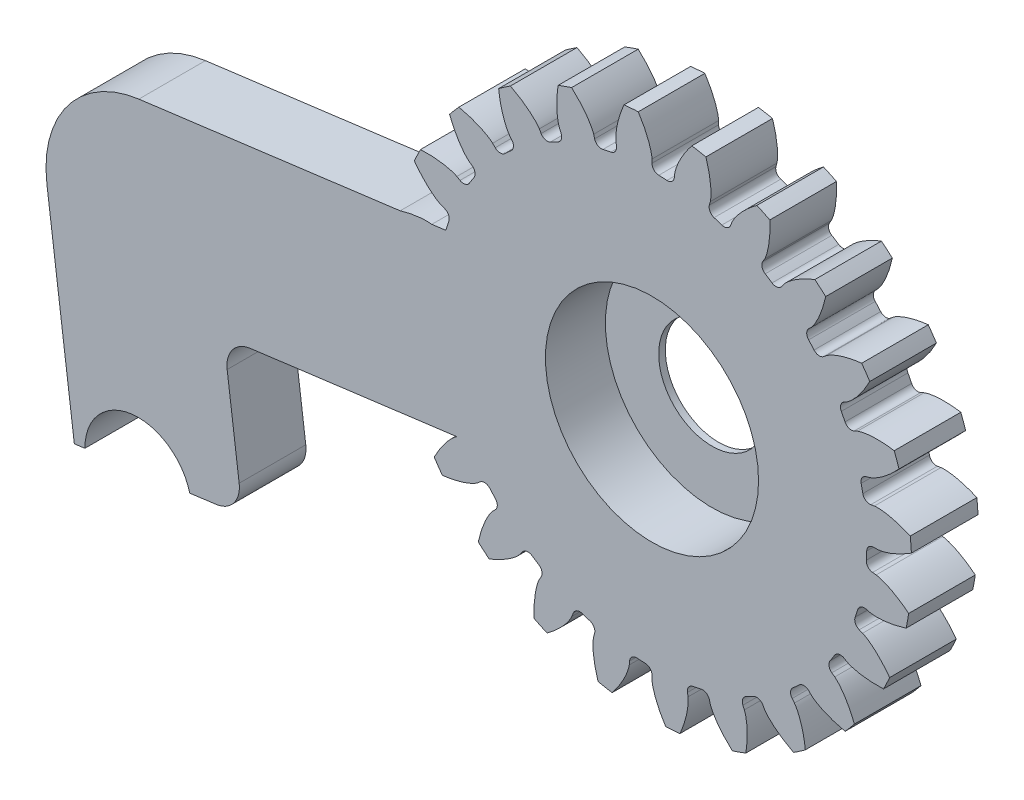
from build123d import *

# Parameters (mm, degrees)
SKETCH_1_R                       = 19.5
EXTRUDE_1_DEPTH                  = 2.5
CUT_EXTRUDE_1_DEPTH              = 3.5
FILLET_1_R                       = 0.525
PATTERN_CIRCULAR_1_COUNT         = 24
FILLET_1_OF_PATTERN_CIRCULAR_1_R = 0.525
SKETCH_7_R                       = 1.25
CUT_EXTRUDE_3_DEPTH              = 10
SKETCH_8_R                       = 8
CUT_EXTRUDE_4_DEPTH              = 4.5
SKETCH_9_R                       = 4
CUT_EXTRUDE_5_DEPTH              = 4
EXTRUDE_2_DEPTH                  = 5
FILLET_2_R                       = 2
FILLET_3_R                       = 2
FILLET_4_R                       = 8


with BuildPart() as part:
    # 草图1 → 凸台-拉伸1 (new body, symmetric)
    with BuildSketch(Plane.XY):
        Circle(SKETCH_1_R)
    extrude(amount=EXTRUDE_1_DEPTH, both=True)

    # 草图4 → 切除-拉伸1 (cut, symmetric)
    with BuildSketch(Plane.XY):
        with BuildLine():
            Line((16.914467174, 0), (16.125, 0))
            ThreePointArc((16.125, 0), (16.104406002, -0.814697695), (16.04267661, -1.627314412))
            Line((16.04267661, -1.627314412), (16.828113296, -1.706986431))
            add(Edge.make_bspline(
                [(16.828113296, -1.706986431), (16.840527681, -1.708511688), (16.875237155, -1.713601645), (16.940385284, -1.72642548), (17.04578575, -1.75185716), (17.178580785, -1.790840016), (17.348168256, -1.848696583), (17.54500963, -1.926359478), (17.757874619, -2.021535782), (17.985348853, -2.135522507), (18.208357518, -2.258343877), (18.426895804, -2.389194021), (18.640882701, -2.526970155), (18.895429995, -2.702464535), (19.193996006, -2.924767557), (19.532565422, -3.201386652), (19.903721108, -3.534555431), (20.267325509, -3.894072436), (20.612744384, -4.264002566), (20.9466773, -4.655469783), (21.259020212, -5.046739901), (21.567017581, -5.470150923), (21.843015964, -5.869742666), (22.133182877, -6.335114454), (22.361853272, -6.715951293), (22.58164624, -7.123307329), (22.686172139, -7.323587215), (22.738546637, -7.426768909)],
                knots=[0, 0, 0, 0, 0, 0.005376748, 0.015083688, 0.02853182, 0.046610139, 0.064854849, 0.092110525, 0.119476175, 0.146842495, 0.174208853, 0.201574955, 0.228941013, 0.256307345, 0.307035032, 0.361767351, 0.41649966, 0.471231936, 0.525964281, 0.580696615, 0.635428982, 0.690161387, 0.744893688, 0.799626083, 0.854358408, 0.909088956, 0.909088956, 0.909088956, 0.909088956, 0.909088956], degree=4))
            ThreePointArc((22.738546637, -7.426768909), (23.890118663, -1.208565197), (23.371958967, 5.094107734))
            add(Edge.make_bspline(
                [(16.914467174, 0), (16.926972094, 0.000264626), (16.962018003, 0.001825759), (17.02812763, 0.008009448), (17.13555642, 0.02267439), (17.271607462, 0.048056683), (17.446167779, 0.088503263), (17.649841661, 0.1459046), (17.87122477, 0.219112829), (18.109040851, 0.309561074), (18.343305751, 0.409249507), (18.573933354, 0.517376858), (18.800731774, 0.632854149), (19.07168996, 0.781763773), (19.391165969, 0.972800693), (19.755922635, 1.213839224), (20.158806113, 1.507850097), (20.556835908, 1.828836711), (20.937823927, 2.162018534), (21.309558148, 2.517786612), (21.659792724, 2.875537433), (22.008947584, 3.265703576), (22.323863042, 3.635401372), (22.659513149, 4.069113436), (22.925449576, 4.424928384), (23.185230209, 4.808023009), (23.309434429, 4.996731535), (23.371958967, 5.094107734)],
                knots=[0, 0, 0, 0, 0, 0.005376748, 0.015083688, 0.02853182, 0.046610139, 0.064854849, 0.092110525, 0.119476175, 0.146842495, 0.174208853, 0.201574955, 0.228941013, 0.256307345, 0.307035032, 0.361767351, 0.41649966, 0.471231936, 0.525964281, 0.580696615, 0.635428982, 0.690161387, 0.744893688, 0.799626083, 0.854358408, 0.909090916, 0.909090916, 0.909090916, 0.909090916, 0.909090916], degree=4))
        make_face()
    cut_extrude_1 = extrude(amount=CUT_EXTRUDE_1_DEPTH, both=True, mode=Mode.SUBTRACT)

    # 圆角1
    fillet_1_edges = [part.edges().sort_by_distance(p)[0] for p in [
        (16.04267661, -1.627314412, 0),
        (16.125, 0, 0),
    ]]
    fillet(fillet_1_edges, radius=FILLET_1_R)

    # 阵列(圆周)1: 切除-拉伸1 ×24 about axis
    pattern_circular_1_axis = Axis((0, 0, 2.5), (0, 0, -1))
    for i in range(1, PATTERN_CIRCULAR_1_COUNT):
        add(cut_extrude_1.rotate(pattern_circular_1_axis, i * 360 / PATTERN_CIRCULAR_1_COUNT), mode=Mode.SUBTRACT)

    # 圆角1 of 阵列(圆周)1
    fillet_1_of_pattern_circular_1_edges = [part.edges().sort_by_distance(p)[0] for p in [
        (15.074855698, -5.724015259, 0),
        (15.575553949, -4.173457102, 0),
        (13.079708283, -9.430633926, 0),
        (13.964659636, -8.0625, 0),
        (10.193200363, -12.494570475, 0),
        (11.402096847, -11.402096847, 0),
        (6.612042684, -14.707022695, 0),
        (8.0625, -13.964659636, 0),
        (2.580285223, -15.917215622, 0),
        (4.173457102, -15.575553949, 0),
        (-1.627314412, -16.04267661, 0),
        (0, -16.125, 0),
        (-5.724015259, -15.074855698, 0),
        (-4.173457102, -15.575553949, 0),
        (-9.430633926, -13.079708283, 0),
        (-8.0625, -13.964659636, 0),
        (-12.494570475, -10.193200363, 0),
        (-11.402096847, -11.402096847, 0),
        (-14.707022695, -6.612042684, 0),
        (-13.964659636, -8.0625, 0),
        (-15.917215622, -2.580285223, 0),
        (-15.575553949, -4.173457102, 0),
        (-16.04267661, 1.627314412, 0),
        (-16.125, 0, 0),
        (-15.074855698, 5.724015259, 0),
        (-15.575553949, 4.173457102, 0),
        (-13.079708283, 9.430633926, 0),
        (-13.964659636, 8.0625, 0),
        (-10.193200363, 12.494570475, 0),
        (-11.402096847, 11.402096847, 0),
        (-6.612042684, 14.707022695, 0),
        (-8.0625, 13.964659636, 0),
        (-2.580285223, 15.917215622, 0),
        (-4.173457102, 15.575553949, 0),
        (1.627314412, 16.04267661, 0),
        (0, 16.125, 0),
        (5.724015259, 15.074855698, 0),
        (4.173457102, 15.575553949, 0),
        (9.430633926, 13.079708283, 0),
        (8.0625, 13.964659636, 0),
        (12.494570475, 10.193200363, 0),
        (11.402096847, 11.402096847, 0),
        (14.707022695, 6.612042684, 0),
        (13.964659636, 8.0625, 0),
        (15.917215622, 2.580285223, 0),
        (15.575553949, 4.173457102, 0),
    ]]
    fillet(fillet_1_of_pattern_circular_1_edges, radius=FILLET_1_OF_PATTERN_CIRCULAR_1_R)

    # 草图7 → 切除-拉伸3 (cut)
    with BuildSketch(Plane.XY.offset(2.5)):
        Circle(SKETCH_7_R)
    extrude(amount=-CUT_EXTRUDE_3_DEPTH, mode=Mode.SUBTRACT)

    # 草图8 → 切除-拉伸4 (cut)
    with BuildSketch(Plane.XY.offset(2.5)):
        Circle(SKETCH_8_R)
    extrude(amount=-CUT_EXTRUDE_4_DEPTH, mode=Mode.SUBTRACT)

    # 草图9 → 切除-拉伸5 (cut)
    with BuildSketch(Plane.XY.offset(-2)):
        Circle(SKETCH_9_R)
    extrude(amount=-CUT_EXTRUDE_5_DEPTH, mode=Mode.SUBTRACT)

    # 草图10 → 凸台-拉伸2 (add)
    with BuildSketch(Plane.XY.offset(2.5)):
        with BuildLine():
            Line((-44.779702092, -12.370459998), (-43.36295053, -23.278842784))
            Line((-43.36295053, -23.278842784), (-42.5696136, -23.175806307))
            ThreePointArc((-42.5696136, -23.175806307), (-39.084825271, -19.193815561), (-34.698467766, -22.153522951))
            Line((-34.698467766, -22.153522951), (-30.731783116, -21.638340565))
            Line((-30.731783116, -21.638340565), (-32.148534678, -10.729957779))
            Line((-32.148534678, -10.729957779), (-13.046224896, -8.249000908))
            Line((-13.046224896, -8.249000908), (-14.720567651, 4.642724203))
            Line((-14.720567651, 4.642724203), (-46.454044847, 0.521265113))
            Line((-46.454044847, 0.521265113), (-44.779702092, -12.370459998))
        make_face()
    extrude(amount=-EXTRUDE_2_DEPTH)

    # 圆角2
    fillet_2_edges = [part.edges().sort_by_distance(p)[0] for p in [
        (-32.148534678, -10.729957779, 0),
    ]]
    fillet(fillet_2_edges, radius=FILLET_2_R)

    # 圆角3
    fillet_3_edges = [part.edges().sort_by_distance(p)[0] for p in [
        (-30.731783116, -21.638340565, 0),
    ]]
    fillet(fillet_3_edges, radius=FILLET_3_R)

    # 圆角4
    fillet_4_edges = [part.edges().sort_by_distance(p)[0] for p in [
        (-46.454044847, 0.521265113, 0),
    ]]
    fillet(fillet_4_edges, radius=FILLET_4_R)


solid = part.part
